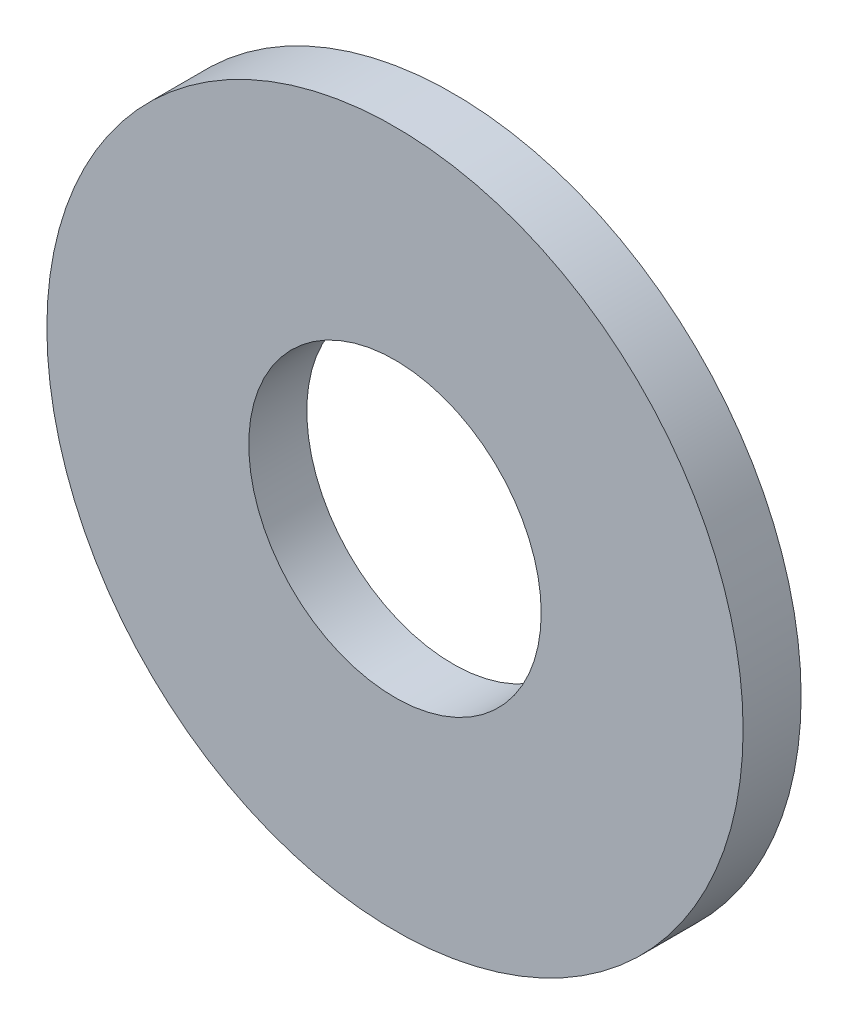
from build123d import *

# Parameters (mm, degrees)
SKETCH1_R           = 9.525
SKETCH1_R_2         = 4.0005
BOSS_EXTRUDE1_DEPTH = 1.5875


with BuildPart() as part:
    # Sketch1 → Boss-Extrude1 (new body)
    with BuildSketch(Plane.XY):
        Circle(SKETCH1_R)
        Circle(SKETCH1_R_2, mode=Mode.SUBTRACT)
    extrude(amount=BOSS_EXTRUDE1_DEPTH)


solid = part.part
